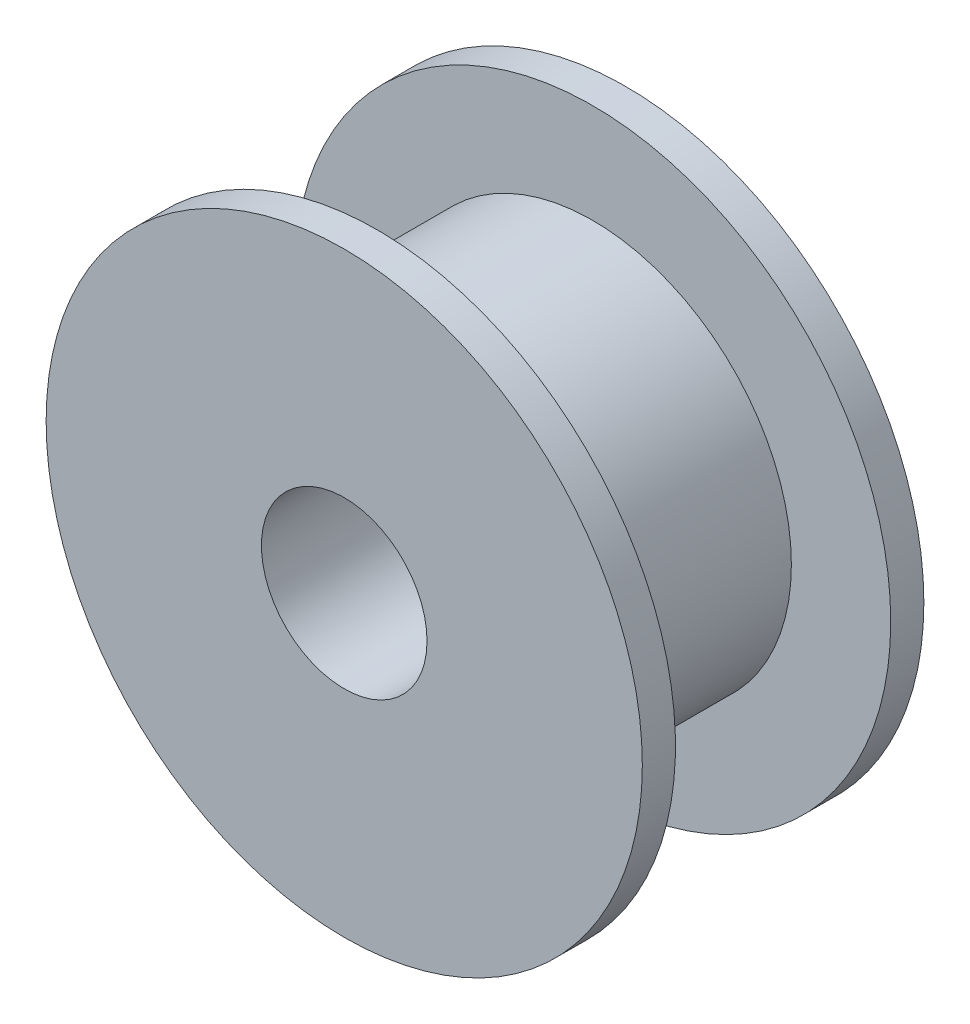
from build123d import *

# Parameters (mm, degrees)
SKETCH2_R           = 9
SKETCH2_R_2         = 2.5
BOSS_EXTRUDE1_DEPTH = 8.5
SKETCH4_W           = 6.5
SKETCH4_H           = 3.782064458


with BuildPart() as part:
    # Sketch2 → Boss-Extrude1 (new body)
    with BuildSketch(Plane.XY):
        Circle(SKETCH2_R)
        Circle(SKETCH2_R_2, mode=Mode.SUBTRACT)
    extrude(amount=BOSS_EXTRUDE1_DEPTH)

    # Sketch4 → Cut-Revolve1 (revolve, cut)
    with BuildSketch(Plane(origin=(0, 0, 0), x_dir=(0, 0, -1), z_dir=(1, 0, 0))):
        with Locations((-4.25, 7.891032229)):
            Rectangle(SKETCH4_W, SKETCH4_H)
    revolve(axis=Axis((0, 0, 8.5), (0, 0, -1)), mode=Mode.SUBTRACT)


solid = part.part
